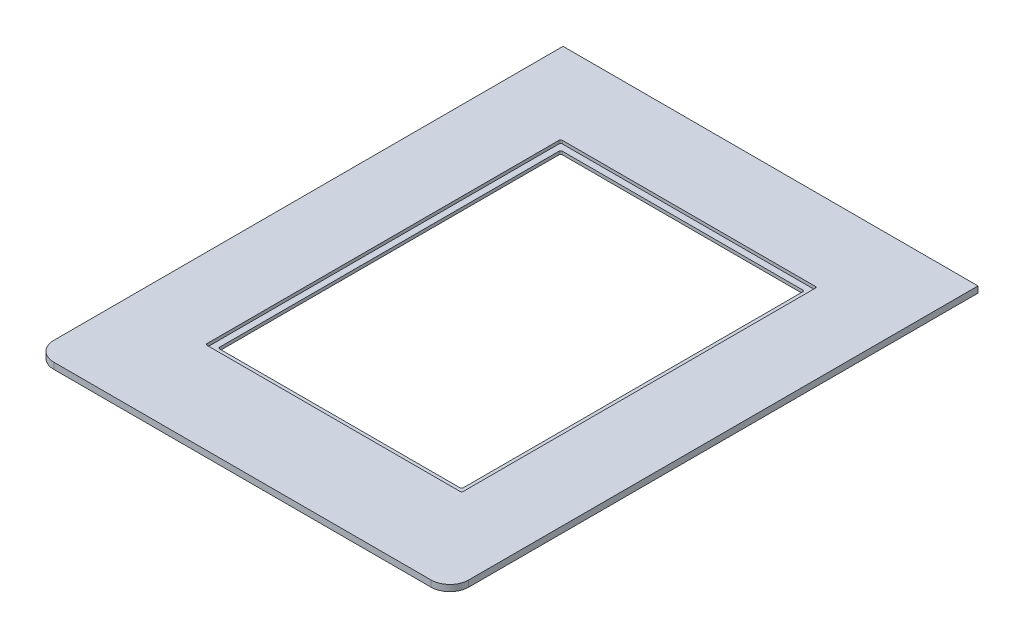
from build123d import *

# Parameters (mm, degrees)
SKETCH1_W             = 419.1
SKETCH1_H             = 533.4
SKETCH1_W_2           = 246.0625
SKETCH1_H_2           = 346.075
OVERALL_SHAPE_DEPTH   = 6.35
SKETCH5_W             = 258.7625
SKETCH5_H             = 358.775
GLASS_INSET_CUT_DEPTH = 3.175
GLASS_INSET_FILLETS_R = 1.5875
FILLET1_R             = 19.05


with BuildPart() as part:
    # Sketch1 → Overall shape (new body)
    with BuildSketch(Plane(origin=(0, 0, 0), x_dir=(1, 0, 0), z_dir=(0, 1, 0))):
        with Locations((209.55, 266.7)):
            Rectangle(SKETCH1_W, SKETCH1_H)
        with Locations((209.55, 271.4625)):
            Rectangle(SKETCH1_W_2, SKETCH1_H_2, mode=Mode.SUBTRACT)
    extrude(amount=OVERALL_SHAPE_DEPTH)

    # Sketch5 → Glass inset cut (cut)
    with BuildSketch(Plane(origin=(0, 6.35, 0), x_dir=(1, 0, 0), z_dir=(0, 1, 0))):
        with Locations((209.55, 271.4625)):
            Rectangle(SKETCH5_W, SKETCH5_H)
    extrude(amount=-GLASS_INSET_CUT_DEPTH, mode=Mode.SUBTRACT)

    # Glass inset fillets
    glass_inset_fillets_edges = [part.edges().sort_by_distance(p)[0] for p in [
        (332.58125, 1.5875, -444.5),
        (86.51875, 1.5875, -444.5),
        (332.58125, 1.5875, -98.425),
        (86.51875, 1.5875, -98.425),
        (80.16875, 4.7625, -92.075),
        (80.16875, 4.7625, -450.85),
        (338.93125, 4.7625, -450.85),
        (338.93125, 4.7625, -92.075),
    ]]
    fillet(glass_inset_fillets_edges, radius=GLASS_INSET_FILLETS_R)

    # Fillet1
    fillet1_edges = [part.edges().sort_by_distance(p)[0] for p in [
        (419.1, 3.175, 0),
        (0, 3.175, 0),
    ]]
    fillet(fillet1_edges, radius=FILLET1_R)


solid = part.part
